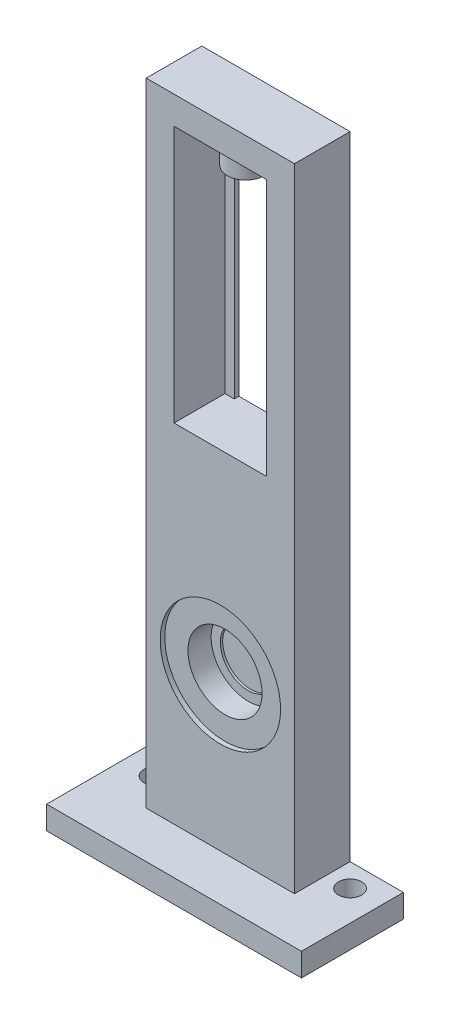
from build123d import *

# Parameters (mm, degrees)
MAINFRAME_DEPTH             = 11
GUIDEBACKBOARD_DEPTH        = 1
SKETCH3_W                   = 32
SKETCH3_H                   = 12
LOWELENGTH_DEPTH            = 80
SKETCH4_R                   = 8
LOWERCUT_BEARING_HOLE_DEPTH = 6
SKETCH6_R                   = 6
LOWER_BEARING_HOLE1_DEPTH   = 0.5
SKETCH7_R                   = 13
LOWER_BEARING_HOLE_2_DEPTH  = 1
SKETCH11_W                  = 55
SKETCH11_H                  = 5
BOSS_EXTRUDE1_DEPTH         = 10
BOSS_EXTRUDE1_DEPTH_BACK    = 12
SKETCH12_R                  = 2.5
CUT_EXTRUDE5_DEPTH          = 6
SKETCH13_R                  = 4
BOSS_EXTRUDE2_DEPTH         = 5


with BuildPart() as part:
    # Sketch1 → MainFrame (new body)
    with BuildSketch(Plane.XY):
        Polygon((-16, 61.475378035), (16, 61.475378035), (16, 0), (10, 0), (10, 55.475378035), (-10, 55.475378035), (-10, 0), (-16, 0), align=None)
    extrude(amount=MAINFRAME_DEPTH)

    # Sketch2 → GuideBackBoard (add)
    with BuildSketch(Plane(origin=(0, 0, 0), x_dir=(-1, 0, 0), z_dir=(0, 0, -1))):
        Polygon((8, 0), (8, 55.975378035), (-8, 55.975378035), (-8, 0), (-16, 0), (-16, 61.475378035), (16, 61.475378035), (16, 0), align=None)
    extrude(amount=GUIDEBACKBOARD_DEPTH)

    # Sketch3 → LoweLength (add)
    with BuildSketch(Plane.XZ):
        with Locations((0, 5)):
            Rectangle(SKETCH3_W, SKETCH3_H)
    extrude(amount=LOWELENGTH_DEPTH)

    # Sketch4 → LowerCut Bearing Hole (cut)
    with BuildSketch(Plane.XY.offset(11)):
        with Locations((0, -42.024621965)):
            Circle(SKETCH4_R)
    extrude(amount=-LOWERCUT_BEARING_HOLE_DEPTH, mode=Mode.SUBTRACT)

    # Sketch6 → Lower Bearing Hole1 (cut)
    with BuildSketch(Plane.XY.offset(5)):
        with Locations((0, -42.024621965)):
            Circle(SKETCH6_R)
    extrude(amount=-LOWER_BEARING_HOLE1_DEPTH, mode=Mode.SUBTRACT)

    # Sketch7 → Lower Bearing Hole 2 (cut)
    with BuildSketch(Plane.XY.offset(11)):
        with Locations((0, -42.024621965)):
            Circle(SKETCH7_R)
    extrude(amount=-LOWER_BEARING_HOLE_2_DEPTH, mode=Mode.SUBTRACT)

    # Sketch11 → Boss-Extrude1 (add, two sides)
    with BuildSketch(Plane.XY.offset(11)) as boss_extrude1_sk:
        with Locations((0, -77.5)):
            Rectangle(SKETCH11_W, SKETCH11_H)
    extrude(amount=BOSS_EXTRUDE1_DEPTH)
    extrude(boss_extrude1_sk.sketch, amount=-BOSS_EXTRUDE1_DEPTH_BACK)

    # Sketch12 → Cut-Extrude5 (cut, through all)
    with BuildSketch(Plane(origin=(0, -75, 0), x_dir=(1, 0, 0), z_dir=(0, 1, 0))):
        with Locations((21, -4)):
            Circle(SKETCH12_R)
        with Locations((-21, -4)):
            Circle(SKETCH12_R)
    extrude(amount=-CUT_EXTRUDE5_DEPTH, mode=Mode.SUBTRACT)

    # Sketch13 → Boss-Extrude2 (add)
    with BuildSketch(Plane.XZ.offset(-55.475378035)):
        with Locations((0, 5.5)):
            Circle(SKETCH13_R)
    extrude(amount=BOSS_EXTRUDE2_DEPTH)


solid = part.part
